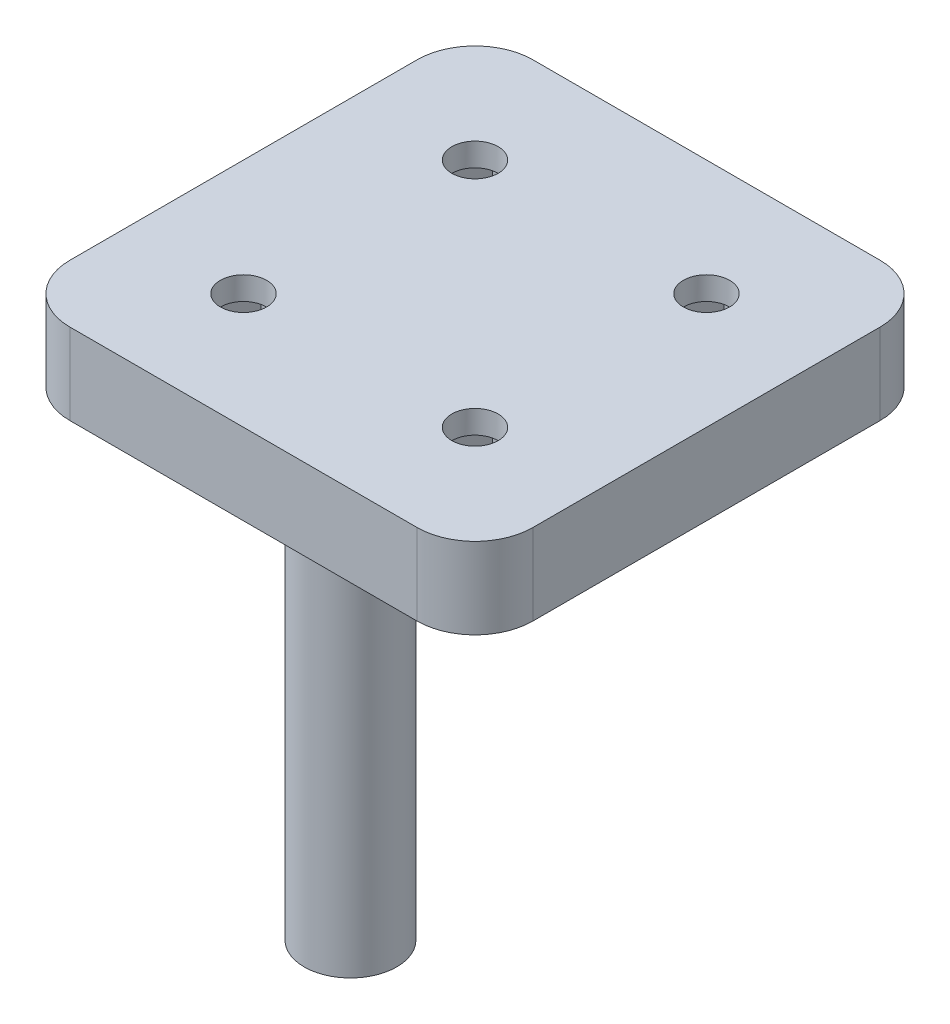
from build123d import *

# Parameters (mm, degrees)
SKETCH1_W           = 40
SKETCH1_H           = 40
BOSS_EXTRUDE1_DEPTH = 7
SKETCH3_R           = 2
CUT_EXTRUDE2_DEPTH  = 8
FILLET1_R           = 5
CUT_EXTRUDE7_DEPTH  = 5
SKETCH4_R           = 4
BOSS_EXTRUDE2_DEPTH = 36
SKETCH5_R           = 2
CUT_EXTRUDE8_DEPTH  = 5


with BuildPart() as part:
    # Sketch1 → Boss-Extrude1 (new body)
    with BuildSketch(Plane(origin=(0, 0, 0), x_dir=(1, 0, 0), z_dir=(0, 1, 0))):
        Rectangle(SKETCH1_W, SKETCH1_H)
    extrude(amount=BOSS_EXTRUDE1_DEPTH)

    # Sketch3 → Cut-Extrude2 (cut, through all)
    with BuildSketch(Plane(origin=(0, 7, 0), x_dir=(1, 0, 0), z_dir=(0, 1, 0))):
        with Locations((-10, 10)):
            Circle(SKETCH3_R)
        with Locations((10, 10)):
            Circle(SKETCH3_R)
        with Locations((-10, -10)):
            Circle(SKETCH3_R)
        with Locations((10, -10)):
            Circle(SKETCH3_R)
    extrude(amount=-CUT_EXTRUDE2_DEPTH, mode=Mode.SUBTRACT)

    # Fillet1
    fillet1_edges = [part.edges().sort_by_distance(p)[0] for p in [
        (20, 3.5, 20),
        (-20, 3.5, 20),
        (-20, 3.5, -20),
        (20, 3.5, -20),
    ]]
    fillet(fillet1_edges, radius=FILLET1_R)

    # Sketch2 → Cut-Extrude7 (cut)
    with BuildSketch(Plane(origin=(0, 0, 0), x_dir=(1, 0, 0), z_dir=(0, 1, 0))):
        Polygon((-5.843078062, -10), (-10, -10), (-10, -6.4), (-12.078460969, -6.4), (-14.156921938, -10), (-12.078460969, -13.6), (-7.921539031, -13.6), align=None)
        Polygon((10, -10), (5.843078062, -10), (7.921539031, -13.6), (12.078460969, -13.6), (14.156921938, -10), (12.078460969, -6.4), (10, -6.4), align=None)
        Polygon((7.921539031, -6.4), (5.843078062, -10), (10, -10), (10, -6.4), align=None)
        Polygon((-10, -6.4), (-10, -10), (-5.843078062, -10), (-7.921539031, -6.4), align=None)
        Polygon((-12.078460969, 6.4), (-10, 6.4), (-10, 10), (-5.843078062, 10), (-7.921539031, 13.6), (-12.078460969, 13.6), (-14.156921938, 10), align=None)
        Polygon((-10, 10), (-10, 6.4), (-7.921539031, 6.4), (-5.843078062, 10), align=None)
        Polygon((7.921539031, 6.4), (10, 6.4), (10, 10), (5.843078062, 10), align=None)
        Polygon((10, 10), (10, 6.4), (12.078460969, 6.4), (14.156921938, 10), (12.078460969, 13.6), (7.921539031, 13.6), (5.843078062, 10), align=None)
    extrude(amount=CUT_EXTRUDE7_DEPTH, mode=Mode.SUBTRACT)

    # Sketch4 → Boss-Extrude2 (add)
    with BuildSketch(Plane(origin=(0, 0, 0), x_dir=(1, 0, 0), z_dir=(0, 1, 0))):
        with Locations((0, -10.76)):
            Circle(SKETCH4_R)
    extrude(amount=-BOSS_EXTRUDE2_DEPTH)

    # Sketch5 → Cut-Extrude8 (cut)
    with BuildSketch(Plane(origin=(0, -36, 0), x_dir=(-1, 0, 0), z_dir=(0, -1, 0))):
        with Locations((0, -10.76)):
            Circle(SKETCH5_R)
    extrude(amount=-CUT_EXTRUDE8_DEPTH, mode=Mode.SUBTRACT)


solid = part.part
